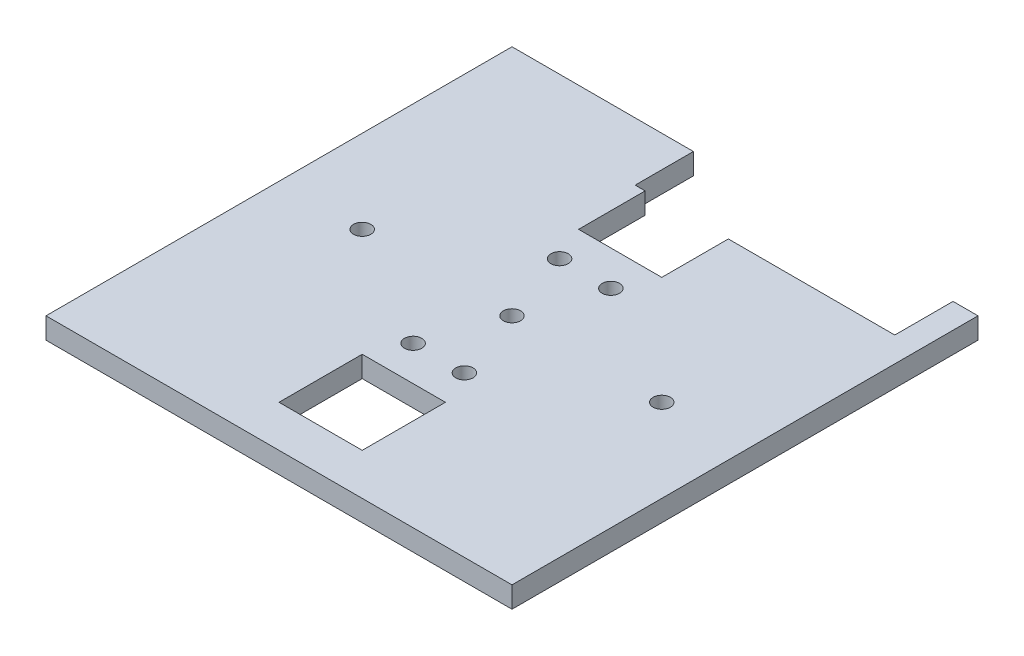
from build123d import *

# Parameters (mm, degrees)
SKETCH1_W           = 225
SKETCH1_H           = 225
BOSS_EXTRUDE1_DEPTH = 6.35
SKETCH2_R           = 1.75
CUT_EXTRUDE1_DEPTH  = 7.35
SKETCH3_R           = 2.6
SKETCH3_W           = 25
SKETCH3_H           = 25
SKETCH3_W_2         = 78
SKETCH3_H_2         = 60
CUT_EXTRUDE2_DEPTH  = 6.35
SKETCH4_W           = 225
SKETCH4_H           = 225
SKETCH4_W_2         = 140
SKETCH4_H_2         = 140
CUT_EXTRUDE3_DEPTH  = 6.35


with BuildPart() as part:
    # Sketch1 → Boss-Extrude1 (new body)
    with BuildSketch(Plane(origin=(0, 0, 0), x_dir=(1, 0, 0), z_dir=(0, 1, 0))):
        with Locations((112.5, 112.5)):
            Rectangle(SKETCH1_W, SKETCH1_H)
    extrude(amount=BOSS_EXTRUDE1_DEPTH)

    # Sketch2 → Cut-Extrude1 (cut, through all)
    with BuildSketch(Plane(origin=(0, 6.35, 0), x_dir=(1, 0, 0), z_dir=(0, 1, 0))):
        with Locations((216.74, 216.74)):
            Circle(SKETCH2_R)
        with Locations((8.26, 216.74)):
            Circle(SKETCH2_R)
        with Locations((216.74, 8.26)):
            Circle(SKETCH2_R)
        with Locations((8.26, 8.26)):
            Circle(SKETCH2_R)
    extrude(amount=-CUT_EXTRUDE1_DEPTH, mode=Mode.SUBTRACT)

    # Sketch3 → Cut-Extrude2 (cut)
    with BuildSketch(Plane(origin=(0, 6.35, 0), x_dir=(1, 0, 0), z_dir=(0, 1, 0))):
        with Locations((157.5, 112.5)):
            Circle(SKETCH3_R)
        with Locations((112.5, 112.5)):
            Circle(SKETCH3_R)
        with Locations((67.5, 112.5)):
            Circle(SKETCH3_R)
        with Locations((120.2, 90.5)):
            Circle(SKETCH3_R)
        with Locations((120.2, 134.5)):
            Circle(SKETCH3_R)
        with Locations((104.8, 134.5)):
            Circle(SKETCH3_R)
        with Locations((104.8, 90.5)):
            Circle(SKETCH3_R)
        with Locations((112.5, 67.5)):
            Rectangle(SKETCH3_W, SKETCH3_H)
        with Locations((136, 195)):
            Rectangle(SKETCH3_W_2, SKETCH3_H_2)
        with Locations((112.5, 157.5)):
            Rectangle(SKETCH3_W, SKETCH3_H)
    extrude(amount=-CUT_EXTRUDE2_DEPTH, mode=Mode.SUBTRACT)

    # Sketch4 → Cut-Extrude3 (cut)
    with BuildSketch(Plane(origin=(0, 6.35, 0), x_dir=(1, 0, 0), z_dir=(0, 1, 0))):
        with Locations((112.5, 112.5)):
            Rectangle(SKETCH4_W, SKETCH4_H)
        with Locations((112.5, 112.5)):
            Rectangle(SKETCH4_W_2, SKETCH4_H_2, mode=Mode.SUBTRACT)
    extrude(amount=-CUT_EXTRUDE3_DEPTH, mode=Mode.SUBTRACT)


solid = part.part
